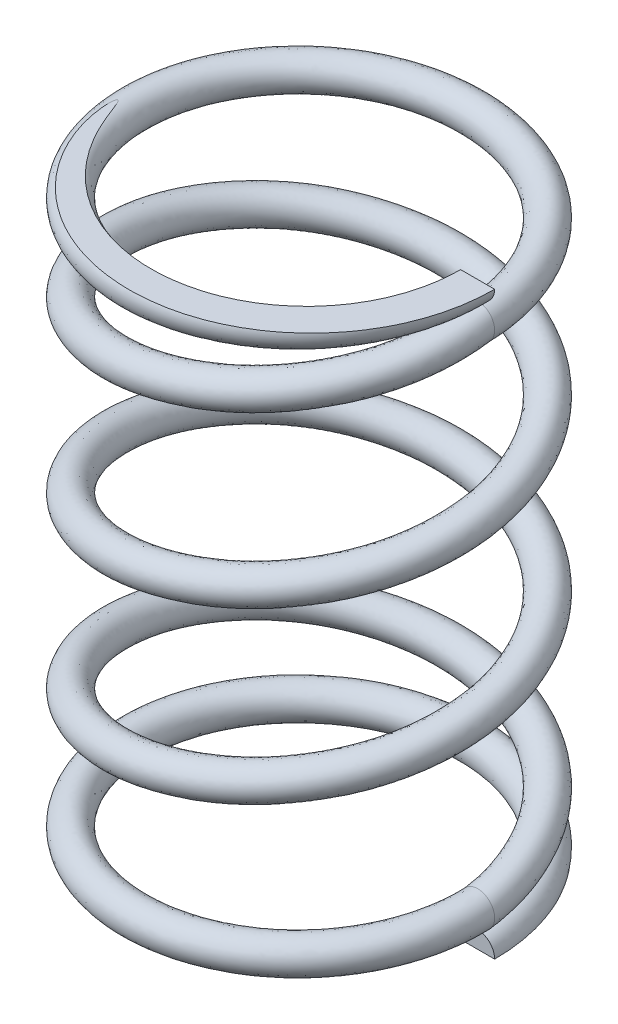
from build123d import *

# Parameters (mm, degrees)
SWEEP1_PITCH       = 2.785533333
SWEEP1_HEIGHT      = 8.3566
SWEEP1_RADIUS      = 3.048
SWEEP1_START_ANGLE = 90
SKETCH1_R          = 0.2794
SWEEP2_PITCH       = 0.5842
SWEEP2_HEIGHT      = 0.5842
SWEEP2_RADIUS      = 3.048
SWEEP2_START_ANGLE = 90
SKETCH5_R          = 0.2794
SWEEP3_PITCH       = 0.5842
SWEEP3_HEIGHT      = 0.5842
SWEEP3_RADIUS      = 3.048
SWEEP3_START_ANGLE = 90
SKETCH7_R          = 0.2794
SKETCH8_W          = 3.048
SKETCH8_H          = 0.2794


with BuildPart() as part:
    # Sweep1: sweep along a helix
    with BuildLine() as sweep1_path:
        add(Helix(SWEEP1_PITCH, SWEEP1_HEIGHT, SWEEP1_RADIUS, center=(0, 0.5842, 0), direction=(0, 1, 0), mode=Mode.PRIVATE).rotate(Axis((0, 0.5842, 0), (0, 1, 0)), SWEEP1_START_ANGLE))
    # Sketch1 → Sweep1 (sweep)
    with BuildSketch(Plane.XY):
        with Locations((2.7686, 0.5842)):
            Circle(SKETCH1_R)
    sweep(path=sweep1_path.line, is_frenet=True)

    # Sweep2: sweep along a helix
    with BuildLine() as sweep2_path:
        add(Helix(SWEEP2_PITCH, SWEEP2_HEIGHT, SWEEP2_RADIUS, center=(0, 0.5842, 0), direction=(0, -1, 0), mode=Mode.PRIVATE).rotate(Axis((0, 0.5842, 0), (0, -1, 0)), SWEEP2_START_ANGLE))
    # Sketch5 → Sweep2 (sweep)
    with BuildSketch(Plane.XY):
        with Locations((2.7686, 0)):
            Circle(SKETCH5_R)
    sweep(path=sweep2_path.line, is_frenet=True)

    # Sweep3: sweep along a helix
    with BuildLine() as sweep3_path:
        add(Helix(SWEEP3_PITCH, SWEEP3_HEIGHT, SWEEP3_RADIUS, center=(0, 8.9408, 0), direction=(0, 1, 0), mode=Mode.PRIVATE).rotate(Axis((0, 8.9408, 0), (0, 1, 0)), SWEEP3_START_ANGLE))
    # Sketch7 → Sweep3 (sweep)
    with BuildSketch(Plane.XY):
        with Locations((2.7686, 8.9408)):
            Circle(SKETCH7_R)
    sweep(path=sweep3_path.line, is_frenet=True)

    # Sketch8 → Cut-Revolve1 (revolve, cut)
    with BuildSketch(Plane.XY):
        with Locations((1.524, 9.6647)):
            Rectangle(SKETCH8_W, SKETCH8_H)
        with Locations((1.524, -0.1397)):
            Rectangle(SKETCH8_W, SKETCH8_H)
    revolve(axis=Axis((0, 0, 0), (0, 1, 0)), mode=Mode.SUBTRACT)


solid = part.part
